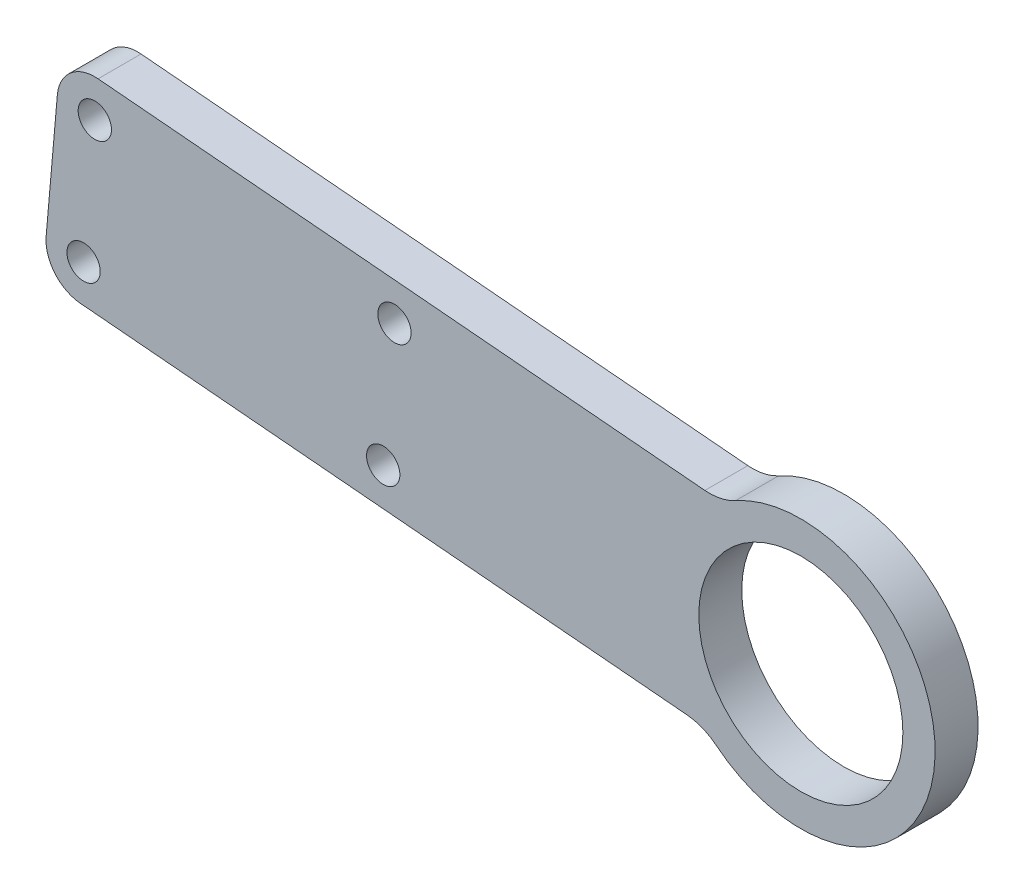
from build123d import *

# Parameters (mm, degrees)
SKETCH_1_R          = 6
EXTRUDE_1_DEPTH     = 2
SKETCH_2_R          = 1.55
SKETCH_2_R_2        = 0.6
CUT_EXTRUDE_1_DEPTH = 5
FILLET_1_R          = 3.5
SKETCH_3_OUTSIDE_W  = 217.41
SKETCH_3_OUTSIDE_H  = 71.355
CUT_EXTRUDE_2_DEPTH = 5
SKETCH_4_R          = 1.55
CUT_EXTRUDE_3_DEPTH = 5
FILLET_2_R          = 3.5
SKETCH_5_R          = 12.5
EXTRUDE_2_DEPTH     = 4
SKETCH_6_R          = 9.5
CUT_EXTRUDE_4_DEPTH = 5
FILLET_3_R          = 5


with BuildPart() as part:
    # 草图1 → 凸台-拉伸1 (new body, symmetric)
    with BuildSketch(Plane.XY):
        with BuildLine():
            Line((-8.927079897, 3.249191362), (-1.4961968, 23.665374879))
            Line((-1.4961968, 23.665374879), (160.827979556, 9.463849632))
            ThreePointArc((160.827979556, 9.463849632), (169.463849632, -0.827979556), (159.172020444, -9.463849632))
            Line((159.172020444, -9.463849632), (11.371578553, 3.467013498))
            Line((11.371578553, 3.467013498), (8.927079897, -3.249191362))
            ThreePointArc((8.927079897, -3.249191362), (-3.249191362, -8.927079897), (-8.927079897, 3.249191362))
        make_face()
        Circle(SKETCH_1_R, mode=Mode.SUBTRACT)
        with Locations((160, 0)):
            Circle(SKETCH_1_R, mode=Mode.SUBTRACT)
    extrude(amount=EXTRUDE_1_DEPTH, both=True)

    # 草图2 → 切除-拉伸1 (cut, through all)
    with BuildSketch(Plane.XY.offset(2)):
        with Locations((0.874182871, 19.944624098)):
            Circle(SKETCH_2_R)
        with Locations((16.220555377, 6.556152427)):
            Circle(SKETCH_2_R)
        with Locations((11.935394126, 3.261801412)):
            Circle(SKETCH_2_R_2)
    extrude(amount=-CUT_EXTRUDE_1_DEPTH, mode=Mode.SUBTRACT)

    # 圆角1
    fillet_1_edges = [part.edges().sort_by_distance(p)[0] for p in [
        (-1.4961968, 23.665374879, 0),
    ]]
    fillet(fillet_1_edges, radius=FILLET_1_R)

    # 草图3 outside → 切除-拉伸2 (cut, through all)
    with BuildSketch(Plane.XY.offset(2)):
        with Locations((80, 6.9725)):
            Rectangle(SKETCH_3_OUTSIDE_W, SKETCH_3_OUTSIDE_H)
        with BuildLine():
            Line((91.09435069, 15.564751624), (89.438391577, -3.36294764))
            Line((89.438391577, -3.36294764), (159.172020444, -9.463849632))
            ThreePointArc((159.172020444, -9.463849632), (169.463849632, -0.827979556), (160.827979556, 9.463849632))
            Line((160.827979556, 9.463849632), (91.09435069, 15.564751624))
        make_face(mode=Mode.SUBTRACT)
    extrude(amount=-CUT_EXTRUDE_2_DEPTH, mode=Mode.SUBTRACT)

    # 草图4 → 切除-拉伸3 (cut, through all)
    with BuildSketch(Plane.XY.offset(2)):
        with Locations((94.275987033, 11.773025081)):
            Circle(SKETCH_4_R)
        with Locations((93.23011812, -0.181311296)):
            Circle(SKETCH_4_R)
        with Locations((122.16943858, 9.332664284)):
            Circle(SKETCH_4_R)
        with Locations((121.123569667, -2.621672093)):
            Circle(SKETCH_4_R)
    extrude(amount=-CUT_EXTRUDE_3_DEPTH, mode=Mode.SUBTRACT)

    # 圆角2
    fillet_2_edges = [part.edges().sort_by_distance(p)[0] for p in [
        (89.438391577, -3.36294764, 0),
        (91.09435069, 15.564751624, 0),
    ]]
    fillet(fillet_2_edges, radius=FILLET_2_R)

    # 草图5 → 凸台-拉伸2 (add)
    with BuildSketch(Plane.XY.offset(2)):
        with Locations((160, 0)):
            Circle(SKETCH_5_R)
    extrude(amount=-EXTRUDE_2_DEPTH)

    # 草图6 → 切除-拉伸4 (cut, through all)
    with BuildSketch(Plane.XY.offset(2)):
        with Locations((160, 0)):
            Circle(SKETCH_6_R)
    extrude(amount=-CUT_EXTRUDE_4_DEPTH, mode=Mode.SUBTRACT)

    # 圆角3
    fillet_3_edges = [part.edges().sort_by_distance(p)[0] for p in [
        (152.73485557, 10.171906233, 0),
        (151.078896458, -8.755793031, 0),
    ]]
    fillet(fillet_3_edges, radius=FILLET_3_R)


solid = part.part
